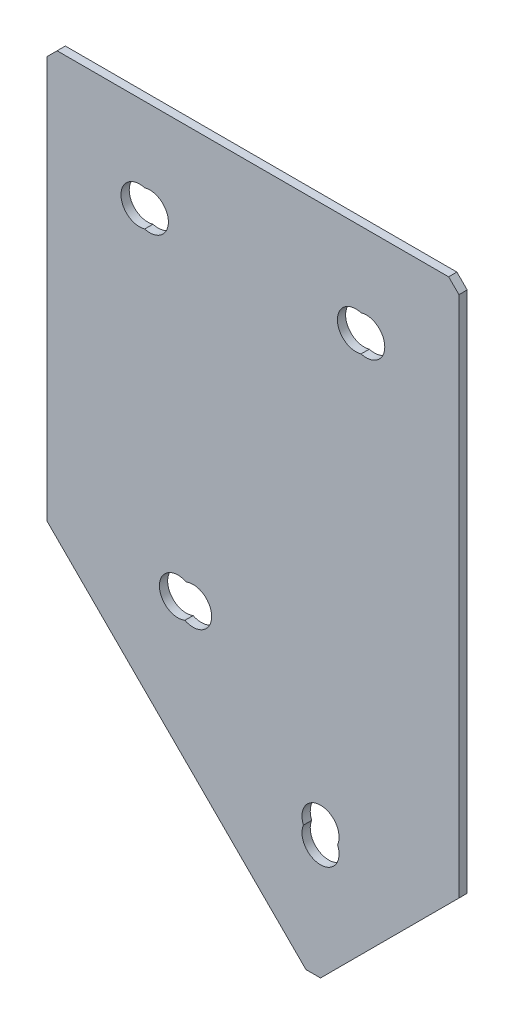
from build123d import *

# Parameters (mm, degrees)
EXTRUDE_1_DEPTH   = 2
HOLE_WIZARD_M81_D = 9
CHAMFER_1_SIZE    = 2.5


with BuildPart() as part:
    # Эскиз3 → Бобышка-Вытянуть1 (new body)
    with BuildSketch(Plane(origin=(0, 0, 0), x_dir=(1, 0, 0), z_dir=(0, 0, -1))):
        Polygon((0, 0), (100, 0), (100, 129.289321881), (64.644660941, 164.644660941), (0, 100), align=None)
    extrude(amount=EXTRUDE_1_DEPTH)

    # Отверстие с зазором M81 (through all)
    with Locations(Plane(origin=(0, 0, -2), x_dir=(1, 0, 0), z_dir=(0, 0, -1))):
        with Locations((22.5, 22.5), (77.5, 22.5), (31.819805153, 100), (66.412427894, 134.59262274), (35.496760416, 100.141421356), (66.412427894, 131.057088834), (25, 22.5), (75, 22.5)):
            Hole(HOLE_WIZARD_M81_D / 2)

    # Фаска1
    chamfer_1_edges = [part.edges().sort_by_distance(p)[0] for p in [
        (64.644660941, -164.644660941, -1),
        (100, 0, -1),
        (0, 0, -1),
    ]]
    chamfer(chamfer_1_edges, length=CHAMFER_1_SIZE)


solid = part.part
